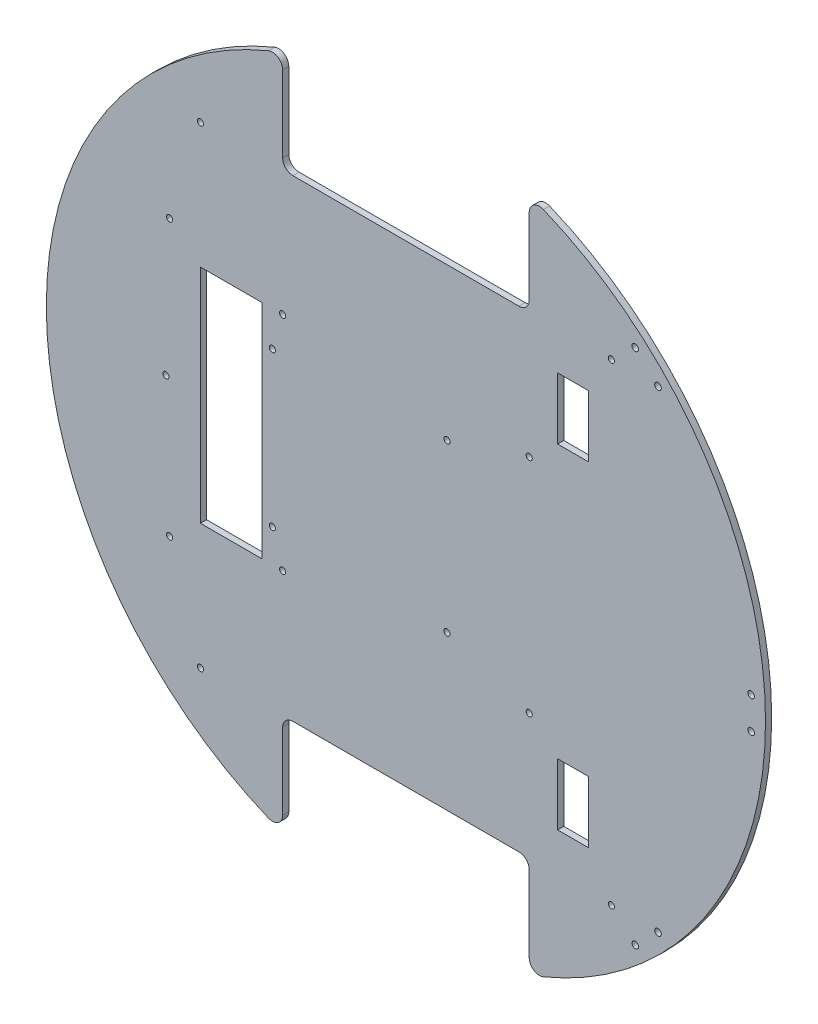
from build123d import *

# Parameters (mm, degrees)
SKETCH_1_R           = 175
EXTRUDE_1_DEPTH      = 3
CUT_EXTRUDE_1_DEPTH  = 3
FILLET_1_R           = 5
FILLET_2_R           = 5
FILLET_3_R           = 5
SKETCH_5_R           = 1.5
CUT_EXTRUDE_4_DEPTH  = 3
SKETCH_6_R           = 1.5
CUT_EXTRUDE_5_DEPTH  = 3
SKETCH_7_W           = 30
SKETCH_7_H           = 108
CUT_EXTRUDE_6_DEPTH  = 3
SKETCH_8_R           = 1.5
CUT_EXTRUDE_7_DEPTH  = 3
SKETCH_9_R           = 1.5
CUT_EXTRUDE_8_DEPTH  = 10
SKETCH_10_R          = 1.6
CUT_EXTRUDE_9_DEPTH  = 10
SKETCH_11_W          = 15
SKETCH_11_H          = 30
CUT_EXTRUDE_10_DEPTH = 10


with BuildPart() as part:
    # ｽｹｯﾁ1 → ﾎﾞｽ - 押し出し1 (new body)
    with BuildSketch(Plane.XY):
        Circle(SKETCH_1_R)
    extrude(amount=EXTRUDE_1_DEPTH)

    # ｽｹｯﾁ2 → ｶｯﾄ - 押し出し1 (cut)
    with BuildSketch(Plane.XY.offset(3)):
        with BuildLine():
            Line((-60, 115), (0, 115))
            Line((0, 115), (0, 175))
            ThreePointArc((0, 175), (-30.465194158, 172.327803749), (-60, 164.392822228))
            Line((-60, 164.392822228), (-60, 115))
        make_face()
        with BuildLine():
            Line((0, 175), (0, 115))
            Line((0, 115), (60, 115))
            Line((60, 115), (60, 164.392822228))
            ThreePointArc((60, 164.392822228), (30.465194158, 172.327803749), (0, 175))
        make_face()
        with BuildLine():
            Line((0, -175), (0, -115))
            Line((0, -115), (-60, -115))
            Line((-60, -115), (-60, -164.392822228))
            ThreePointArc((-60, -164.392822228), (-30.465194158, -172.327803749), (0, -175))
        make_face()
        with BuildLine():
            Line((60, -115), (0, -115))
            Line((0, -115), (0, -175))
            ThreePointArc((0, -175), (30.465194158, -172.327803749), (60, -164.392822228))
            Line((60, -164.392822228), (60, -115))
        make_face()
    extrude(amount=-CUT_EXTRUDE_1_DEPTH, mode=Mode.SUBTRACT)

    # ﾌｨﾚｯﾄ1
    fillet_1_edges = [part.edges().sort_by_distance(p)[0] for p in [
        (-60, 164.392822228, 1.5),
    ]]
    fillet(fillet_1_edges, radius=FILLET_1_R)

    # ﾌｨﾚｯﾄ2
    fillet_2_edges = [part.edges().sort_by_distance(p)[0] for p in [
        (-60, 115, 1.5),
        (60, 164.392822228, 1.5),
        (60, 115, 1.5),
    ]]
    fillet(fillet_2_edges, radius=FILLET_2_R)

    # ﾌｨﾚｯﾄ3
    fillet_3_edges = [part.edges().sort_by_distance(p)[0] for p in [
        (-60, -115, 1.5),
        (60, -115, 1.5),
        (60, -164.392822228, 1.5),
        (-60, -164.392822228, 1.5),
    ]]
    fillet(fillet_3_edges, radius=FILLET_3_R)

    # ｽｹｯﾁ5 → ｶｯﾄ - 押し出し4 (cut)
    with BuildSketch(Plane.XY.offset(3)):
        with Locations((-100, -115)):
            Circle(SKETCH_5_R)
        with Locations((100, -115)):
            Circle(SKETCH_5_R)
        with Locations((100, 115)):
            Circle(SKETCH_5_R)
        with Locations((-100, 115)):
            Circle(SKETCH_5_R)
    extrude(amount=-CUT_EXTRUDE_4_DEPTH, mode=Mode.SUBTRACT)

    # ｽｹｯﾁ6 → ｶｯﾄ - 押し出し5 (cut)
    with BuildSketch(Plane.XY.offset(3)):
        with Locations((-60, 54)):
            Circle(SKETCH_6_R)
        with Locations((60, 54)):
            Circle(SKETCH_6_R)
        with Locations((-60, -54)):
            Circle(SKETCH_6_R)
        with Locations((60, -54)):
            Circle(SKETCH_6_R)
    extrude(amount=-CUT_EXTRUDE_5_DEPTH, mode=Mode.SUBTRACT)

    # ｽｹｯﾁ7 → ｶｯﾄ - 押し出し6 (cut)
    with BuildSketch(Plane.XY.offset(3)):
        with Locations((-85, 0)):
            Rectangle(SKETCH_7_W, SKETCH_7_H)
    extrude(amount=-CUT_EXTRUDE_6_DEPTH, mode=Mode.SUBTRACT)

    # ｽｹｯﾁ8 → ｶｯﾄ - 押し出し7 (cut)
    with BuildSketch(Plane.XY.offset(3)):
        with Locations((-115, -67)):
            Circle(SKETCH_8_R)
        with Locations((-116.822468618, 0)):
            Circle(SKETCH_8_R)
        with Locations((-115, 67)):
            Circle(SKETCH_8_R)
    extrude(amount=-CUT_EXTRUDE_7_DEPTH, mode=Mode.SUBTRACT)

    # ｽｹｯﾁ9 → ｶｯﾄ - 押し出し8 (cut)
    with BuildSketch(Plane.XY.offset(3)):
        with Locations((-65, 37)):
            Circle(SKETCH_9_R)
        with Locations((20, 41)):
            Circle(SKETCH_9_R)
        with Locations((-65, -38)):
            Circle(SKETCH_9_R)
        with Locations((20, -40)):
            Circle(SKETCH_9_R)
    extrude(amount=-CUT_EXTRUDE_8_DEPTH, mode=Mode.SUBTRACT)

    # ｽｹｯﾁ10 → ｶｯﾄ - 押し出し9 (cut)
    with BuildSketch(Plane.XY.offset(3)):
        with Locations((111.643659725, -125.921059639)):
            Circle(SKETCH_10_R)
        with Locations((122.679794489, -115.037952538)):
            Circle(SKETCH_10_R)
        with Locations((168, 7.75)):
            Circle(SKETCH_10_R)
        with Locations((168, -7.75)):
            Circle(SKETCH_10_R)
        with Locations((111.56768007, 125.844011632)):
            Circle(SKETCH_10_R)
        with Locations((122.679794489, 115.037952538)):
            Circle(SKETCH_10_R)
    extrude(amount=-CUT_EXTRUDE_9_DEPTH, mode=Mode.SUBTRACT)

    # ｽｹｯﾁ11 → ｶｯﾄ - 押し出し10 (cut)
    with BuildSketch(Plane.XY.offset(3)):
        with Locations((81.317279836, 81.317279836)):
            Rectangle(SKETCH_11_W, SKETCH_11_H)
        with Locations((81.317279836, -81.317279836)):
            Rectangle(SKETCH_11_W, SKETCH_11_H)
    extrude(amount=-CUT_EXTRUDE_10_DEPTH, mode=Mode.SUBTRACT)


solid = part.part
